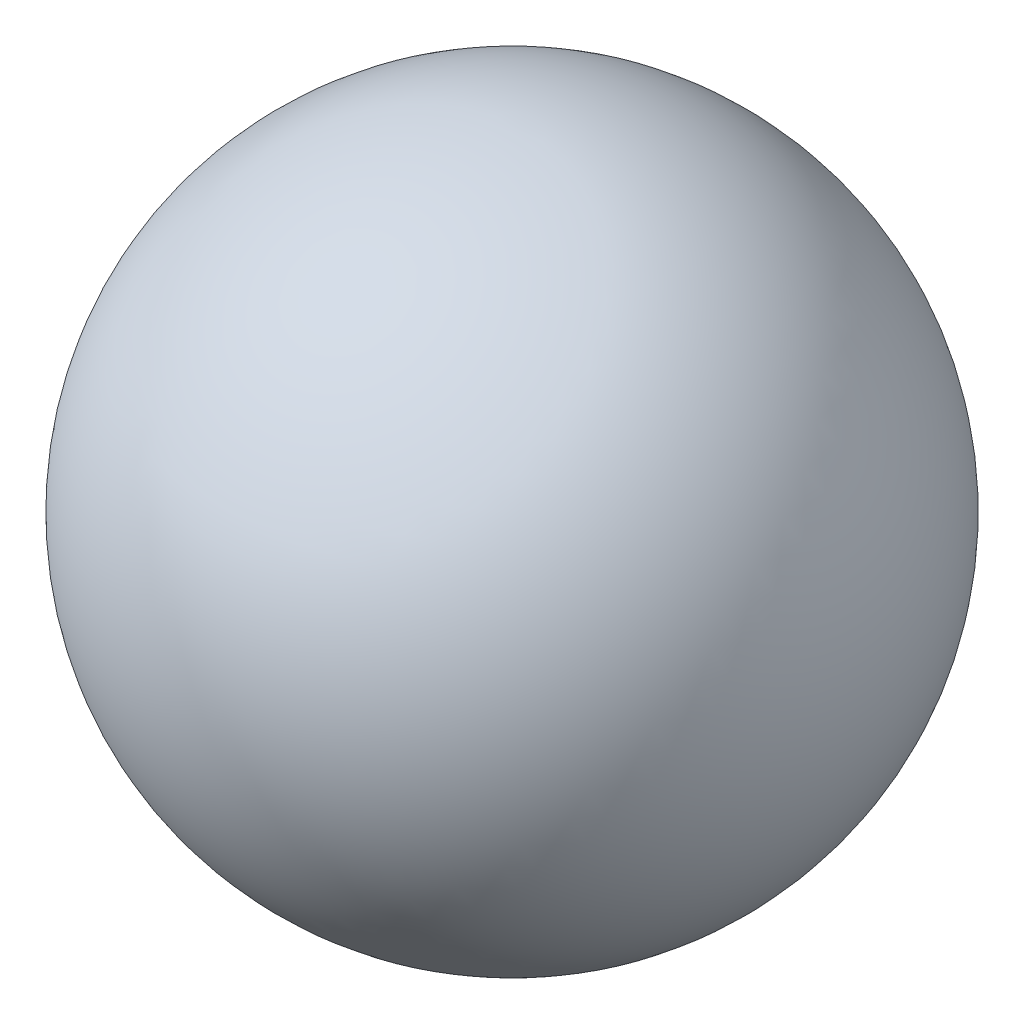
from build123d import *


with BuildPart() as part:
    # Sketch1 → Revolve-Thin8 (revolve)
    with BuildSketch(Plane.XY):
        with BuildLine():
            Line((0, 900), (0, -900))
            ThreePointArc((0, -900), (900, 0), (0, 900))
        make_face()
        with BuildLine():
            Line((10, 889.943818451), (10, -889.943818451))
            ThreePointArc((10, -889.943818451), (890, 0), (10, 889.943818451))
        make_face(mode=Mode.SUBTRACT)
    revolve(axis=Axis((0, 900, 0), (0, -1, 0)))


solid = part.part
